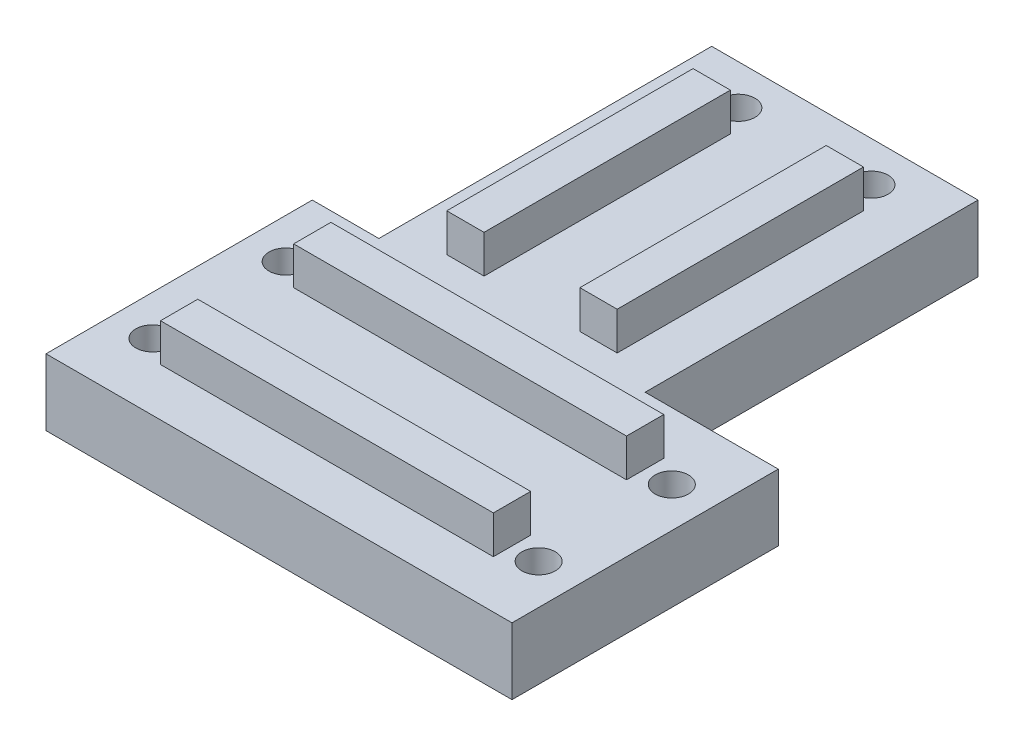
from build123d import *

# Parameters (mm, degrees)
SALIENTE_EXTRUIR1_DEPTH = 10
SALIENTE_EXTRUIR3_DEPTH = 100
CROQUIS5_W              = 40
CROQUIS5_H              = 50
SALIENTE_EXTRUIR5_DEPTH = 10
SALIENTE_EXTRUIR7_DEPTH = 47
CROQUIS13_W             = 59.276280914
CROQUIS13_H             = 44.398623438
CORTAR_EXTRUIR4_DEPTH   = 30
CROQUIS14_R             = 2.5
CORTAR_EXTRUIR5_DEPTH   = 16.7
CROQUIS15_W             = 10
CROQUIS15_H             = 40
CROQUIS15_W_2           = 40
CROQUIS15_H_2           = 10
CORTAR_EXTRUIR6_DEPTH   = 6.7


with BuildPart() as part:
    # Croquis1 → Saliente-Extruir1 (new body)
    with BuildSketch(Plane(origin=(0, 0, 0), x_dir=(1, 0, 0), z_dir=(0, 1, 0))):
        Polygon((20, 20), (-30, 20), (-30, -20), (40, -20), (70, -20), (70, 20), align=None)
    extrude(amount=SALIENTE_EXTRUIR1_DEPTH)

    # Croquis3 → Saliente-Extruir3 (add)
    with BuildSketch(Plane.ZY.offset(30)):
        Polygon((10, 10), (12.8, 10), (12.8, 15.7), (7.2, 15.7), (7.2, 10), align=None)
        Polygon((-10, 10), (-7.2, 10), (-7.2, 15.7), (-12.8, 15.7), (-12.8, 10), align=None)
    extrude(amount=-SALIENTE_EXTRUIR3_DEPTH)

    # Croquis5 → Saliente-Extruir5 (add)
    with BuildSketch(Plane(origin=(0, 10, 0), x_dir=(1, 0, 0), z_dir=(0, 1, 0))):
        with Locations((0, 45)):
            Rectangle(CROQUIS5_W, CROQUIS5_H)
    extrude(amount=-SALIENTE_EXTRUIR5_DEPTH)

    # Croquis7 → Saliente-Extruir7 (add)
    with BuildSketch(Plane(origin=(0, 0, -70), x_dir=(-1, 0, 0), z_dir=(0, 0, -1))):
        Polygon((-10, 10), (-12.8, 10), (-12.8, 15.7), (-7.2, 15.7), (-7.2, 10), align=None)
        Polygon((10, 10), (7.2, 10), (7.2, 15.7), (12.8, 15.7), (12.8, 10), align=None)
    extrude(amount=-SALIENTE_EXTRUIR7_DEPTH)

    # Croquis13 → Cortar-Extruir4 (cut)
    with BuildSketch(Plane(origin=(70, 0, 0), x_dir=(0, 0, -1), z_dir=(1, 0, 0))):
        Rectangle(CROQUIS13_W, CROQUIS13_H)
    extrude(amount=-CORTAR_EXTRUIR4_DEPTH, mode=Mode.SUBTRACT)

    # Croquis14 → Cortar-Extruir5 (cut, through all)
    with BuildSketch(Plane(origin=(0, 0, 0), x_dir=(-1, 0, 0), z_dir=(0, -1, 0))):
        with Locations((-34, -10)):
            Circle(CROQUIS14_R)
        with Locations((-34, 10)):
            Circle(CROQUIS14_R)
        with Locations((24, -10)):
            Circle(CROQUIS14_R)
        with Locations((24, 10)):
            Circle(CROQUIS14_R)
        with Locations((10, 64)):
            Circle(CROQUIS14_R)
        with Locations((-10, 64)):
            Circle(CROQUIS14_R)
    extrude(amount=-CORTAR_EXTRUIR5_DEPTH, mode=Mode.SUBTRACT)

    # Croquis15 → Cortar-Extruir6 (cut, through all)
    with BuildSketch(Plane(origin=(0, 10, 0), x_dir=(1, 0, 0), z_dir=(0, 1, 0))):
        with Locations((35, 0)):
            Rectangle(CROQUIS15_W, CROQUIS15_H)
        with Locations((-25, 0)):
            Rectangle(CROQUIS15_W, CROQUIS15_H)
        with Locations((0, 65)):
            Rectangle(CROQUIS15_W_2, CROQUIS15_H_2)
    extrude(amount=CORTAR_EXTRUIR6_DEPTH, mode=Mode.SUBTRACT)


solid = part.part
